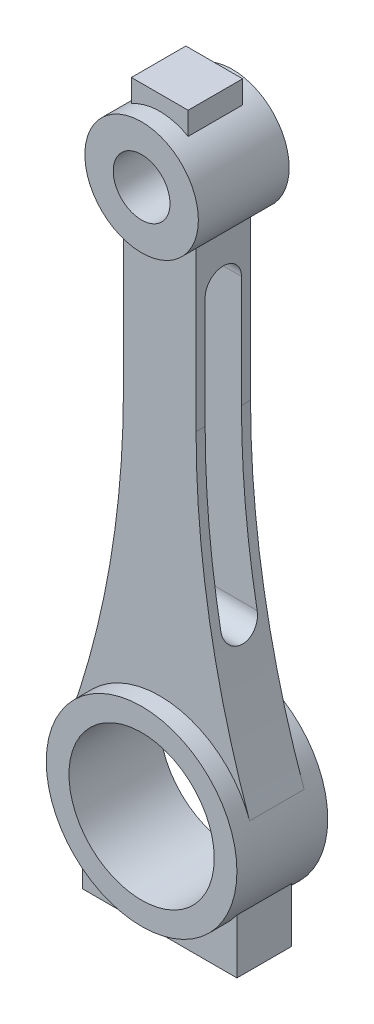
from build123d import *

# Parameters (mm, degrees)
SKETCH1_R               = 12.5
SKETCH1_R_2             = 6.25
BOSS_EXTRUDE1_DEPTH     = 10
SKETCH1_R_3             = 21
SKETCH1_R_4             = 16
BOSS_EXTRUDE1_2_DEPTH   = 10
BOSS_EXTRUDE2_DEPTH     = 6
CUT_EXTRUDE1_DEPTH      = 138.802456026
CUT_EXTRUDE1_DEPTH_BACK = 144.802456026
CUT_EXTRUDE1_START      = 6


with BuildPart() as part:
    # Sketch1 → Boss-Extrude1 (new, symmetric)
    with BuildSketch(Plane.XY):
        with Locations((0, 120)):
            Circle(SKETCH1_R)
        with Locations((0, 120)):
            Circle(SKETCH1_R_2, mode=Mode.SUBTRACT)
    extrude(amount=BOSS_EXTRUDE1_DEPTH, both=True)



with BuildPart() as body_2:
    # Sketch1 → Boss-Extrude1 2 (new, symmetric)
    with BuildSketch(Plane.XY):
        Circle(SKETCH1_R_3)
        Circle(SKETCH1_R_4, mode=Mode.SUBTRACT)
    extrude(amount=BOSS_EXTRUDE1_2_DEPTH, both=True)


with BuildPart() as part_1:
    add(part.part)

    add(body_2.part)  # Boss-Extrude2 merges body 2
    # Sketch1_4 → Boss-Extrude2 (add, symmetric)
    with BuildSketch(Plane.XY):
        with BuildLine():
            Line((6.25, 135.825317547), (-6.25, 135.825317547))
            Line((-6.25, 135.825317547), (-6.25, 130.825317547))
            ThreePointArc((-6.25, 130.825317547), (0, 132.5), (6.25, 130.825317547))
            Line((6.25, 130.825317547), (6.25, 135.825317547))
        make_face()
        with BuildLine():
            Line((-8, 110.395313644), (-8, 75.395313644))
            ThreePointArc((-8, 75.395313644), (-10.96842855, 40.709642053), (-19.787382488, 7.032744434))
            ThreePointArc((-19.787382488, 7.032744434), (0, 21), (19.787382488, 7.032744434))
            ThreePointArc((19.787382488, 7.032744434), (10.96842855, 40.709642053), (8, 75.395313644))
            Line((8, 75.395313644), (8, 110.395313644))
            ThreePointArc((8, 110.395313644), (0, 107.5), (-8, 110.395313644))
        make_face()
        with BuildLine():
            Line((-17, -12.328828006), (-17, -24.328828006))
            Line((-17, -24.328828006), (17, -24.328828006))
            Line((17, -24.328828006), (17, -12.328828006))
            ThreePointArc((17, -12.328828006), (0, -21), (-17, -12.328828006))
        make_face()
    extrude(amount=BOSS_EXTRUDE2_DEPTH, both=True)

    # Sketch2 → Cut-Extrude1 (cut, two sides: drawn at the far end of the back side and taken through both)
    with BuildSketch(Plane(origin=(0, 0, 0), x_dir=(0, 0, -1), z_dir=(1, 0, 0)).offset(CUT_EXTRUDE1_START - CUT_EXTRUDE1_DEPTH_BACK)):
        with BuildLine():
            Line((4, 100), (4, 38))
            ThreePointArc((4, 38), (0, 34), (-4, 38))
            Line((-4, 38), (-4, 100))
            ThreePointArc((-4, 100), (0, 104), (4, 100))
        make_face()
    extrude(amount=CUT_EXTRUDE1_DEPTH + CUT_EXTRUDE1_DEPTH_BACK, mode=Mode.SUBTRACT)


solid = part_1.part
